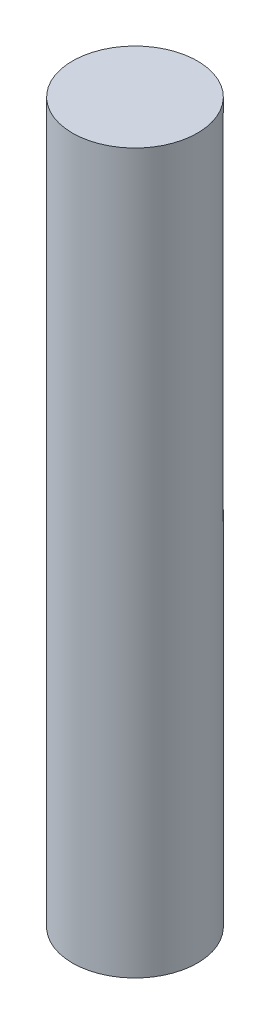
from build123d import *

# Parameters (mm, degrees)
SKETCH1_R           = 8
BOSS_EXTRUDE1_DEPTH = 46
BOSS_EXTRUDE2_DEPTH = 44
SKETCH3_R           = 8
BOSS_EXTRUDE3_DEPTH = 2


with BuildPart() as part:
    # Sketch1 → Boss-Extrude1 (new body)
    with BuildSketch(Plane(origin=(0, 0, 0), x_dir=(1, 0, 0), z_dir=(0, 1, 0))):
        Circle(SKETCH1_R)
    extrude(amount=BOSS_EXTRUDE1_DEPTH)

    # Sketch2 → Boss-Extrude2 (add)
    with BuildSketch(Plane(origin=(0, 46, 0), x_dir=(1, 0, 0), z_dir=(0, 1, 0))):
        with BuildLine():
            Line((-6.079473661, 5.2), (6.079473661, 5.2))
            ThreePointArc((6.079473661, 5.2), (0, -8), (-6.079473661, 5.2))
        make_face()
    extrude(amount=BOSS_EXTRUDE2_DEPTH)

    # Sketch3 → Boss-Extrude3 (add)
    with BuildSketch(Plane(origin=(0, 90, 0), x_dir=(1, 0, 0), z_dir=(0, 1, 0))):
        Circle(SKETCH3_R)
    extrude(amount=BOSS_EXTRUDE3_DEPTH)


solid = part.part
